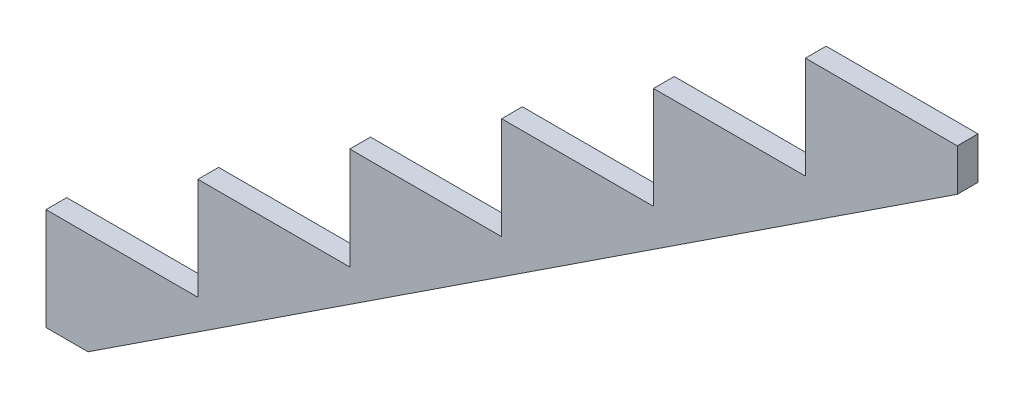
from build123d import *

# Parameters (mm, degrees)
BOSS_EXTRUDE1_DEPTH = 38.1


with BuildPart() as part:
    # Sketch1 → Boss-Extrude1 (new body)
    with BuildSketch(Plane.XY):
        Polygon((0, 187.96), (0, 0), (77.248154039, 0), (1676.4, 1050.511845961), (1676.4, 1127.76), (1397, 1127.76), (1397, 939.8), (1117.6, 939.8), (1117.6, 751.84), (838.2, 751.84), (838.2, 563.88), (558.8, 563.88), (558.8, 375.92), (279.4, 375.92), (279.4, 187.96), align=None)
    extrude(amount=BOSS_EXTRUDE1_DEPTH)


solid = part.part
